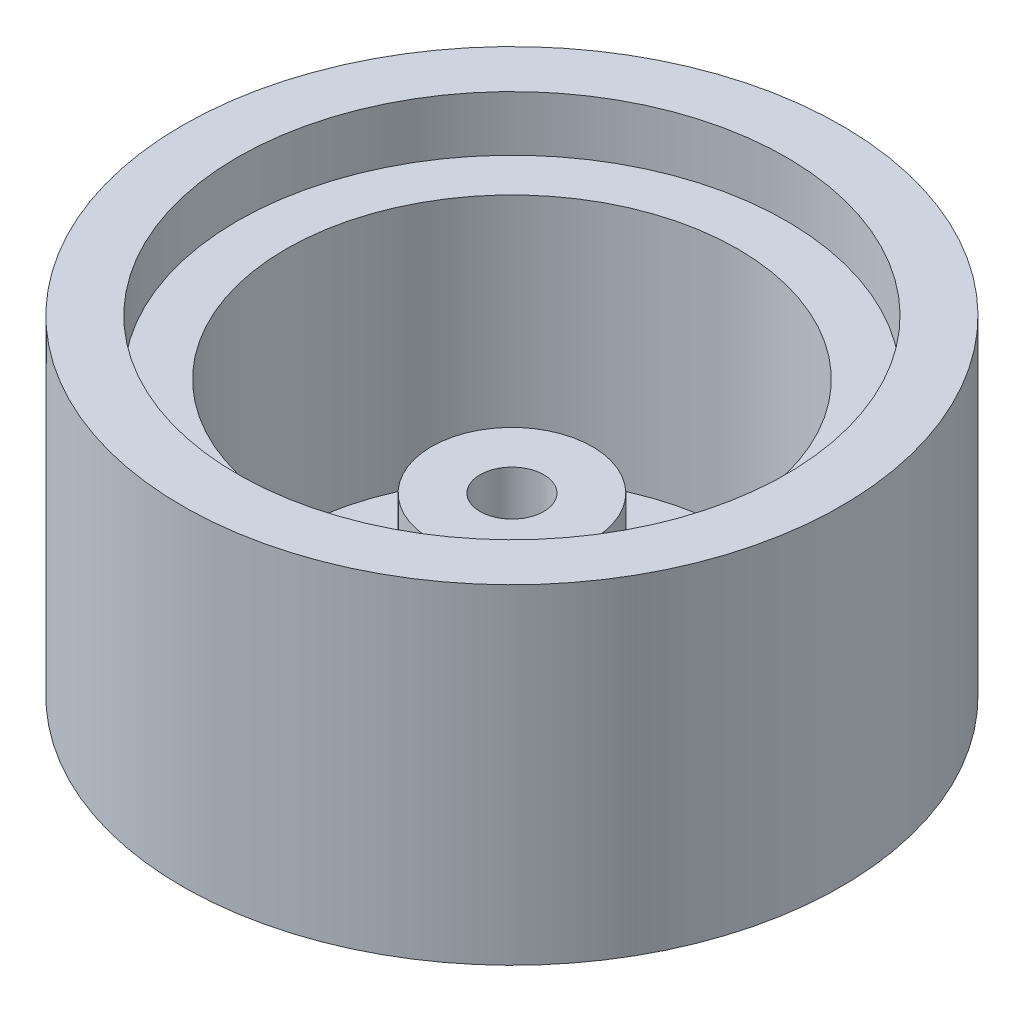
from build123d import *


with BuildPart() as part:
    # Sketch1 → Revolve1 (revolve)
    with BuildSketch(Plane.XY):
        Polygon((20.9, -10.592120945), (7.45, -10.592120945), (7.45, 3.087879055), (2.95, 3.087879055), (2.95, -13.192120945), (30.5, -13.192120945), (30.5, 17.307879055), (25.4, 17.307879055), (25.4, 12.207879055), (20.9, 12.207879055), align=None)
    revolve(axis=Axis((0, 55.694527482, 0), (0, -1, 0)))


solid = part.part
